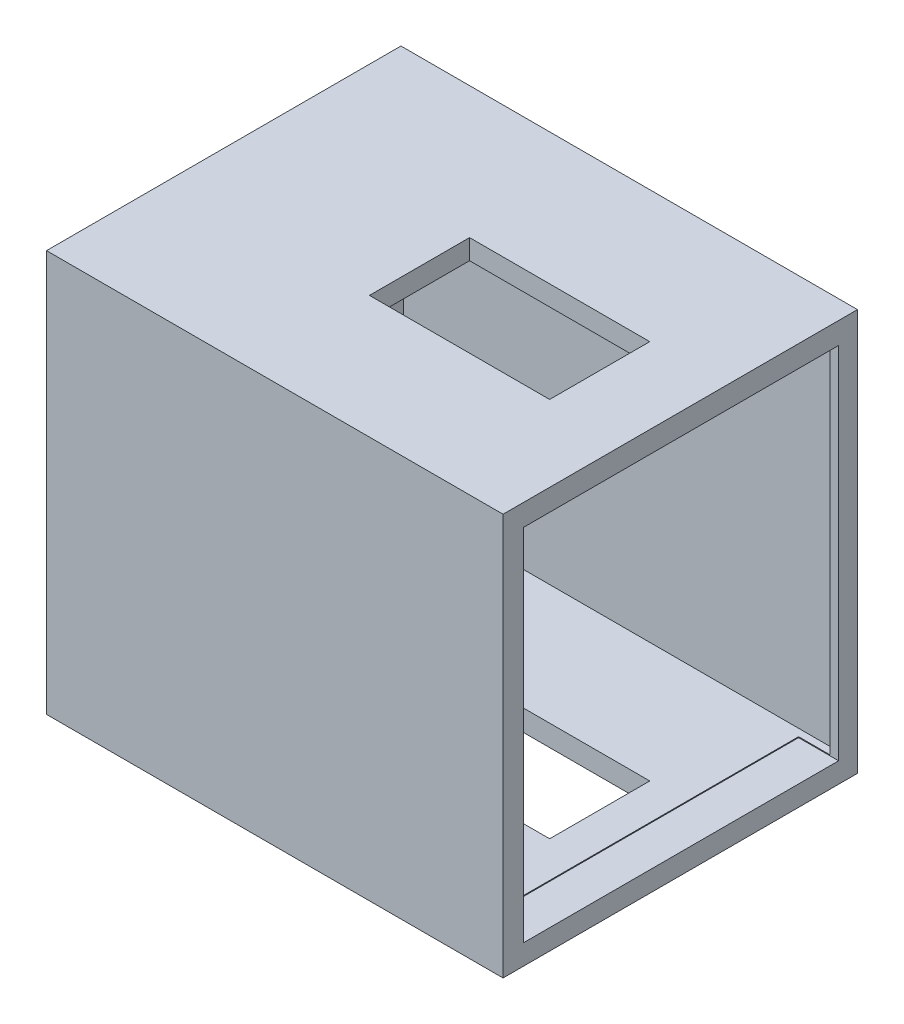
from build123d import *

# Parameters (mm, degrees)
SKETCH1_W           = 228
SKETCH1_H           = 177
SKETCH1_W_2         = 90
SKETCH1_H_2         = 50
BOSS_EXTRUDE2_DEPTH = 200.582631371
CUT_EXTRUDE1_START  = -10
SKETCH2_W           = 108.838399528
SKETCH2_H           = 164.710968607
SKETCH2_W_2         = 60.282653626
SKETCH2_H_2         = 61.539971991
CUT_EXTRUDE1_DEPTH  = 180
SKETCH5_W           = 157.303446562
SKETCH5_H           = 179.645970641
CUT_EXTRUDE2_DEPTH  = 20


with BuildPart() as part:
    # Sketch1 → Boss-Extrude2 (new body)
    with BuildSketch(Plane(origin=(0, 0, 0), x_dir=(1, 0, 0), z_dir=(0, 1, 0))):
        Rectangle(SKETCH1_W, SKETCH1_H)
        with Locations((31, -2.231282948)):
            Rectangle(SKETCH1_W_2, SKETCH1_H_2, mode=Mode.SUBTRACT)
    extrude(amount=BOSS_EXTRUDE2_DEPTH)

    # Sketch2 → Cut-Extrude1 (cut)
    with BuildSketch(Plane(origin=(0, 200.582631371, 0), x_dir=(1, 0, 0), z_dir=(0, 1, 0)).offset(CUT_EXTRUDE1_START)):
        with Locations((-52.521027136, 0.352939873)):
            Rectangle(SKETCH2_W, SKETCH2_H)
        Polygon((109.79292582, 82.708424176), (1.898172628, 82.708424176), (1.898172628, 8.029391403), (62.180826254, 8.029391403), (109.79292582, 8.029391403), align=None)
        with Locations((32.039499441, -51.232558436)):
            Rectangle(SKETCH2_W_2, SKETCH2_H_2)
        Polygon((109.79292582, 8.029391403), (62.180826254, 8.029391403), (62.180826254, -20.46257244), (62.180826254, -82.002544431), (109.79292582, -82.002544431), align=None)
    extrude(amount=-CUT_EXTRUDE1_DEPTH, mode=Mode.SUBTRACT)

    # Sketch5 → Cut-Extrude2 (cut)
    with BuildSketch(Plane(origin=(114, 0, 0), x_dir=(0, 0, -1), z_dir=(1, 0, 0))):
        with Locations((0.425718885, 99.965893577)):
            Rectangle(SKETCH5_W, SKETCH5_H)
    extrude(amount=-CUT_EXTRUDE2_DEPTH, mode=Mode.SUBTRACT)


solid = part.part
